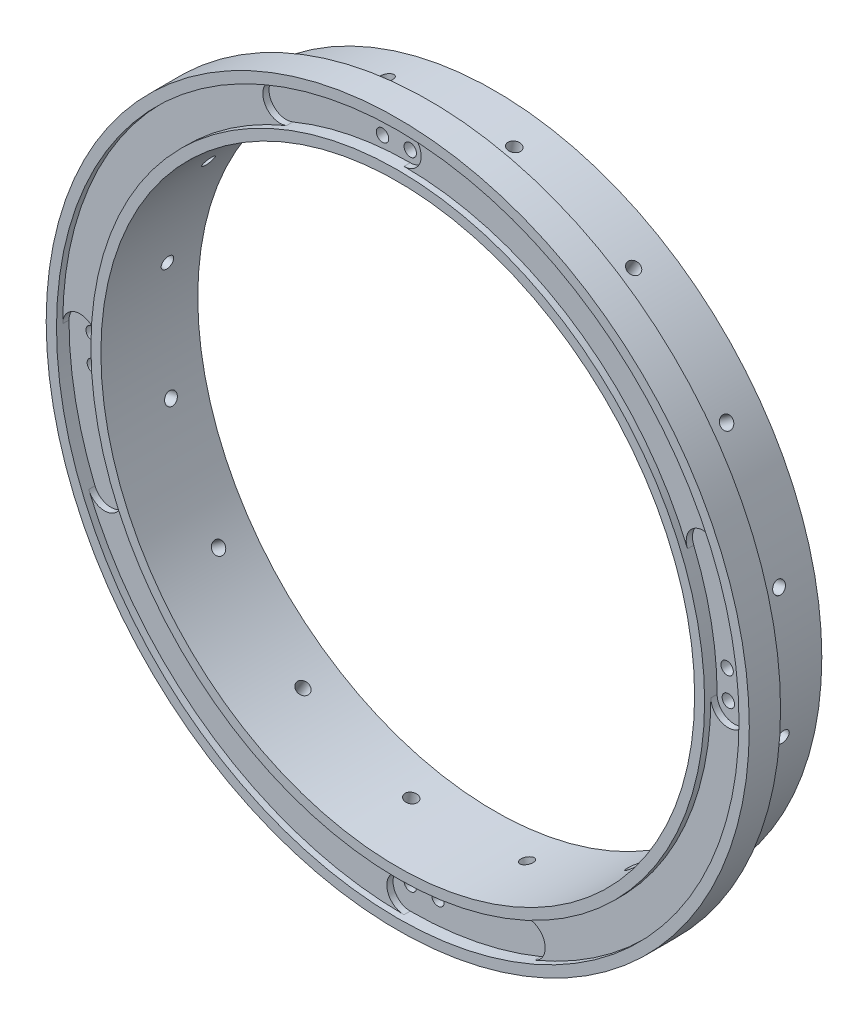
from build123d import *
from build123d.topology import SkipClean

# Parameters (mm, degrees)
SKETCH1_R                    = 71.4375
EXTRUDE1_DEPTH               = 19.685
SKETCH2_R                    = 60.325
EXTRUDE2_DEPTH               = 103.92780012
SKETCH3_OUTSIDE_W            = 185.478
SKETCH3_OUTSIDE_H            = 185.478
SKETCH3_OUTSIDE_R            = 66.4845
EXTRUDE3_DEPTH               = 13.335
SKETCH4_R                    = 69.342
SKETCH4_R_2                  = 62.357
EXTRUDE4_DEPTH               = 1.27
EXTRUDE6_START               = -1.27
EXTRUDE6_DEPTH               = 104.962477999
CIRPATTERN1_COUNT            = 4
F_39_0_0995_DIAMETER_HOLE1_D = 2.5273
CIRPATTERN2_COUNT            = 4
CIRPATTERN4_COUNT            = 16


with BuildPart() as part:
    # Sketch1 → Extrude1 (new body)
    with BuildSketch(Plane.XY):
        Circle(SKETCH1_R)
    extrude(amount=EXTRUDE1_DEPTH)

    # Sketch2 → Extrude2 (cut, through all)
    with BuildSketch(Plane.XY.offset(19.685)):
        Circle(SKETCH2_R)
    extrude(amount=-EXTRUDE2_DEPTH, mode=Mode.SUBTRACT)

    # Sketch3 outside → Extrude3 (cut)
    with BuildSketch(Plane(origin=(0, 0, 0), x_dir=(-1, 0, 0), z_dir=(0, 0, -1))):
        Rectangle(SKETCH3_OUTSIDE_W, SKETCH3_OUTSIDE_H)
        Circle(SKETCH3_OUTSIDE_R, mode=Mode.SUBTRACT)
    extrude(amount=-EXTRUDE3_DEPTH, mode=Mode.SUBTRACT)

    # Sketch4 → Extrude4 (cut)
    with BuildSketch(Plane.XY.offset(19.685)):
        Circle(SKETCH4_R)
        Circle(SKETCH4_R_2, mode=Mode.SUBTRACT)
    extrude(amount=-EXTRUDE4_DEPTH, mode=Mode.SUBTRACT)

    # Sketch7 → Extrude6 (cut)
    with BuildSketch(Plane.XY.offset(18.415).offset(EXTRUDE6_START)):
        with BuildLine():
            ThreePointArc((0, 69.342), (-13.527953109, 68.009612914), (-26.536034567, 64.063654543))
            ThreePointArc((-26.536034567, 64.063654543), (-28.426161947, 59.500483389), (-23.862990792, 57.610356009))
            ThreePointArc((-23.862990792, 57.610356009), (-12.16524721, 61.15882773), (0, 62.357))
            ThreePointArc((0, 62.357), (3.4925, 65.8495), (0, 69.342))
        make_face()
    extrude6 = extrude(amount=EXTRUDE6_DEPTH, mode=Mode.SUBTRACT)

    # CirPattern1: Extrude6 ×4 about axis
    with SkipClean():  # the faces are left unmerged after this step: merging them gives an invalid solid
        cirpattern1_axis = Axis((0, 0, 0), (0, 0, 1))
        for i in range(1, CIRPATTERN1_COUNT):
            add(extrude6.rotate(cirpattern1_axis, i * 360 / CIRPATTERN1_COUNT), mode=Mode.SUBTRACT)

    # #39 (0.0995) Diameter Hole1 (through all)
    with Locations(Plane(origin=(0, 64.632701659, 17.145), x_dir=(1, 0, 0), z_dir=(0, 0, 1))):
        with Locations((0, 0), (-5.633111119, -0.245946943)):
            f_39_0_0995_diameter_hole1 = Hole(F_39_0_0995_DIAMETER_HOLE1_D / 2)

    # CirPattern2: #39 (0.0995) Diameter Hole1 ×4 about axis
    cirpattern2_axis = Axis((0, 0, 0), (0, 0, 1))
    for i in range(1, CIRPATTERN2_COUNT):
        add(f_39_0_0995_diameter_hole1.rotate(cirpattern2_axis, i * 360 / CIRPATTERN2_COUNT), mode=Mode.SUBTRACT)

    # Sketch16 → #39 (0.0995) Diameter Hole5 (revolve, cut)
    with BuildSketch(Plane(origin=(64.780506572, 14.955758373, 6.985), x_dir=(-0.22495105434385887, 0.9743700647852368, 0), z_dir=(0, 0, 1))):
        Polygon((0, 0), (0, 13.459277521), (1.26365, 12.7), (1.26365, 0), align=None)
    f_39_0_0995_diameter_hole5 = revolve(axis=Axis((70.967756484, 16.384197568, 6.985), (-0.9743700647852366, -0.22495105434385881, 0)), mode=Mode.SUBTRACT)

    # CirPattern4: #39 (0.0995) Diameter Hole5 ×16 about axis
    cirpattern4_axis = Axis((0, 0, 0), (0, 0, 1))
    for i in range(1, CIRPATTERN4_COUNT):
        add(f_39_0_0995_diameter_hole5.rotate(cirpattern4_axis, i * 360 / CIRPATTERN4_COUNT), mode=Mode.SUBTRACT)


solid = part.part
